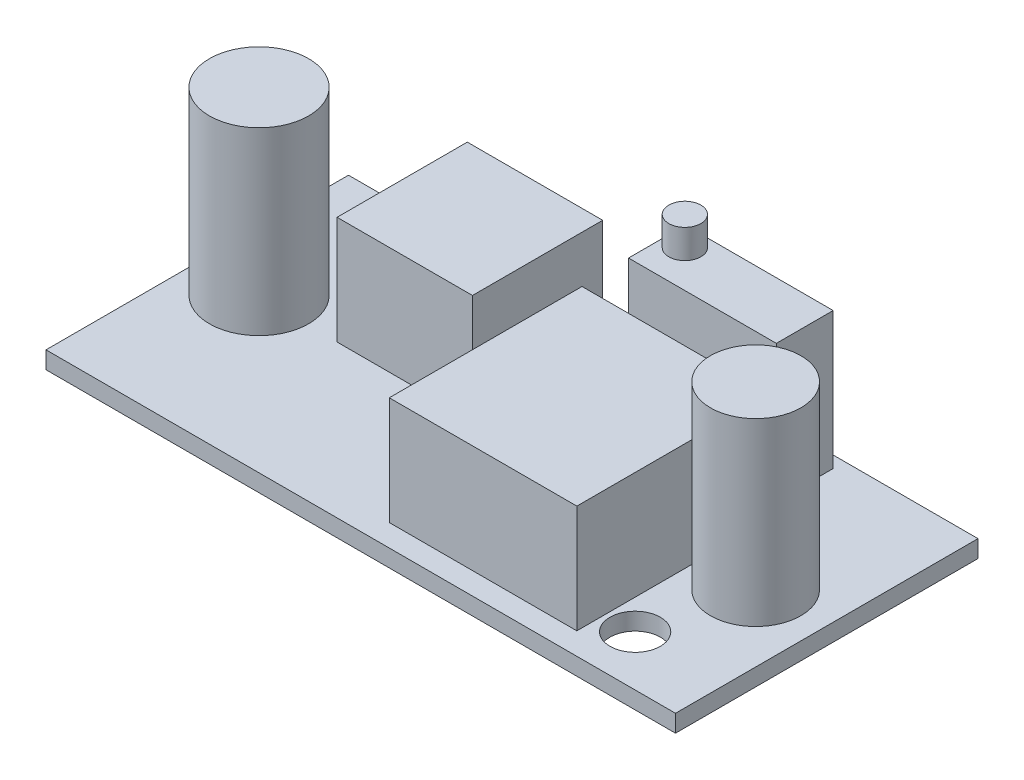
from build123d import *

# Parameters (mm, degrees)
SKETCH1_W           = 43.7
SKETCH1_H           = 21
BOSS_EXTRUDE1_DEPTH = 1.2
SKETCH2_R           = 3.443854009
SKETCH2_R_2         = 3.137647978
BOSS_EXTRUDE2_DEPTH = 12.5
SKETCH3_W           = 13.022072972
SKETCH3_H           = 13.380807765
SKETCH3_W_2         = 9.398851567
SKETCH3_H_2         = 9.040116774
BOSS_EXTRUDE4_DEPTH = 7.5
SKETCH4_W           = 10.259815069
SKETCH4_H           = 3.946082718
BOSS_EXTRUDE5_DEPTH = 9.5
SKETCH5_R           = 1.112077857
BOSS_EXTRUDE6_DEPTH = 2
SKETCH6_R           = 1.75
CUT_EXTRUDE1_DEPTH  = 2


with BuildPart() as part:
    # Sketch1 → Boss-Extrude1 (new body)
    with BuildSketch(Plane(origin=(0, 0, 0), x_dir=(1, 0, 0), z_dir=(0, 1, 0))):
        with Locations((-16.769650206, 2.717901235)):
            Rectangle(SKETCH1_W, SKETCH1_H)
    extrude(amount=BOSS_EXTRUDE1_DEPTH)

    # Sketch2 → Boss-Extrude2 (add)
    with BuildSketch(Plane(origin=(0, 1.2, 0), x_dir=(1, 0, 0), z_dir=(0, 1, 0))):
        with Locations((-34.509085701, 2.897268631)):
            Circle(SKETCH2_R)
        with Locations((0.4316831, 2.4309134)):
            Circle(SKETCH2_R_2)
    extrude(amount=BOSS_EXTRUDE2_DEPTH)

    # Sketch3 → Boss-Extrude4 (add)
    with BuildSketch(Plane(origin=(0, 1.2, 0), x_dir=(1, 0, 0), z_dir=(0, 1, 0))):
        with Locations((-9.810195229, 0.439935301)):
            Rectangle(SKETCH3_W, SKETCH3_H)
        with Locations((-24.285144112, 7.30970658)):
            Rectangle(SKETCH3_W_2, SKETCH3_H_2)
    extrude(amount=BOSS_EXTRUDE4_DEPTH)

    # Sketch4 → Boss-Extrude5 (add)
    with BuildSketch(Plane(origin=(0, 1.2, 0), x_dir=(1, 0, 0), z_dir=(0, 1, 0))):
        with Locations((-9.290029779, 10.430699276)):
            Rectangle(SKETCH4_W, SKETCH4_H)
    extrude(amount=BOSS_EXTRUDE5_DEPTH)

    # Sketch5 → Boss-Extrude6 (add)
    with BuildSketch(Plane(origin=(0, 10.7, 0), x_dir=(1, 0, 0), z_dir=(0, 1, 0))):
        with Locations((-13.092618581, 11.040548423)):
            Circle(SKETCH5_R)
    extrude(amount=BOSS_EXTRUDE6_DEPTH)

    # Sketch6 → Cut-Extrude1 (cut)
    with BuildSketch(Plane(origin=(0, 1.2, 0), x_dir=(1, 0, 0), z_dir=(0, 1, 0))):
        with Locations((-32.119650206, 10.717901235)):
            Circle(SKETCH6_R)
        with Locations((-1.219650206, -4.282098765)):
            Circle(SKETCH6_R)
    extrude(amount=-CUT_EXTRUDE1_DEPTH, mode=Mode.SUBTRACT)


solid = part.part
